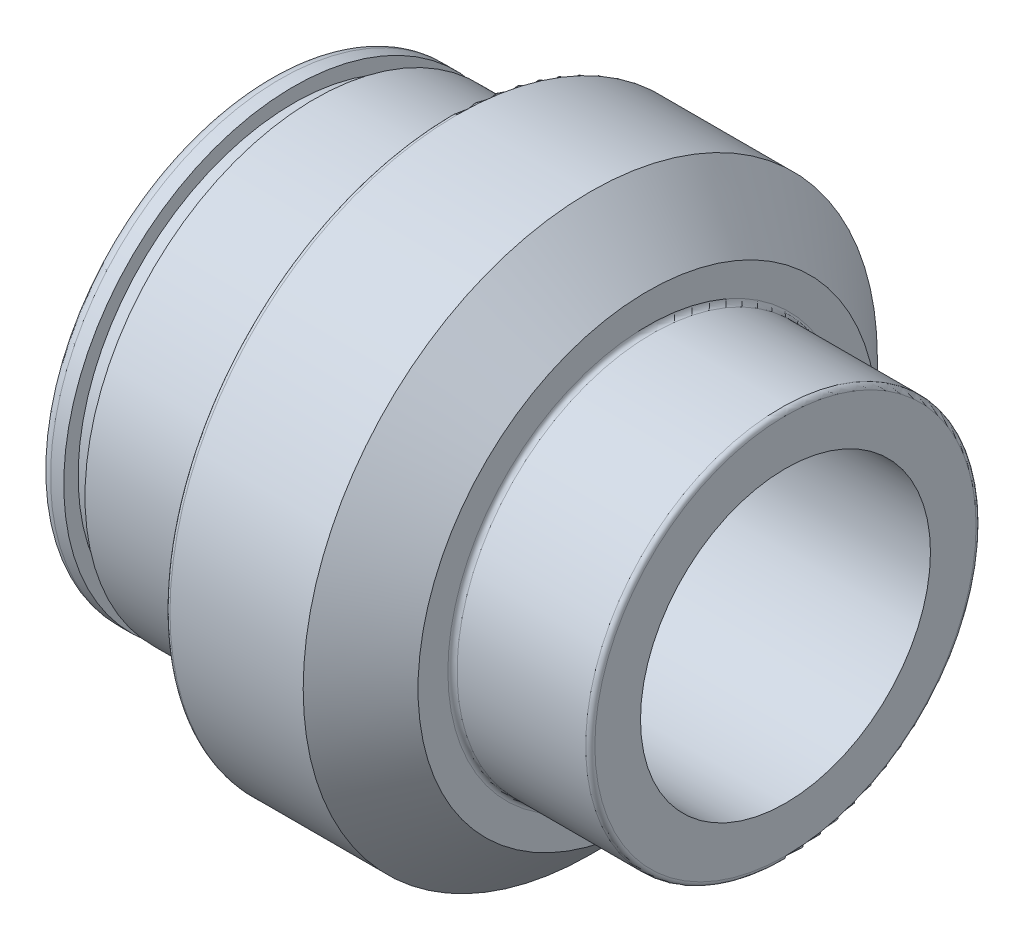
from build123d import *


with BuildPart() as part:
    # Sketch1 → Base-Revolve (revolve)
    with BuildSketch(Plane.XY):
        with BuildLine():
            Line((0, 12.625), (0, 16.6))
            ThreePointArc((0, 16.6), (-0.117157288, 16.882842712), (-0.4, 17))
            Line((-0.4, 17), (-11.6, 17))
            ThreePointArc((-11.6, 17), (-11.882842712, 17.117157288), (-12, 17.4))
            Line((-12, 17.4), (-12, 20))
            Line((-12, 20), (-17, 25))
            Line((-17, 25), (-28.6, 25))
            ThreePointArc((-28.6, 25), (-28.882842712, 24.882842712), (-29, 24.6))
            Line((-29, 24.6), (-29, 20.4))
            ThreePointArc((-29, 20.4), (-29.117157288, 20.117157288), (-29.4, 20))
            Line((-29.4, 20), (-41, 20))
            Line((-41, 20), (-41, 18.75))
            Line((-41, 18.75), (-42.85, 18.75))
            Line((-42.85, 18.75), (-42.85, 20))
            Line((-42.85, 20), (-44, 20))
            ThreePointArc((-44, 20), (-44.707106781, 19.707106781), (-45, 19))
            Line((-45, 19), (-45, 7))
            Line((-45, 7), (-30.247595264, 7))
            Line((-30.247595264, 7), (-27, 12.625))
            Line((-27, 12.625), (0, 12.625))
        make_face()
    revolve(axis=Axis((0, 0, 0), (-1, 0, 0)))


solid = part.part
